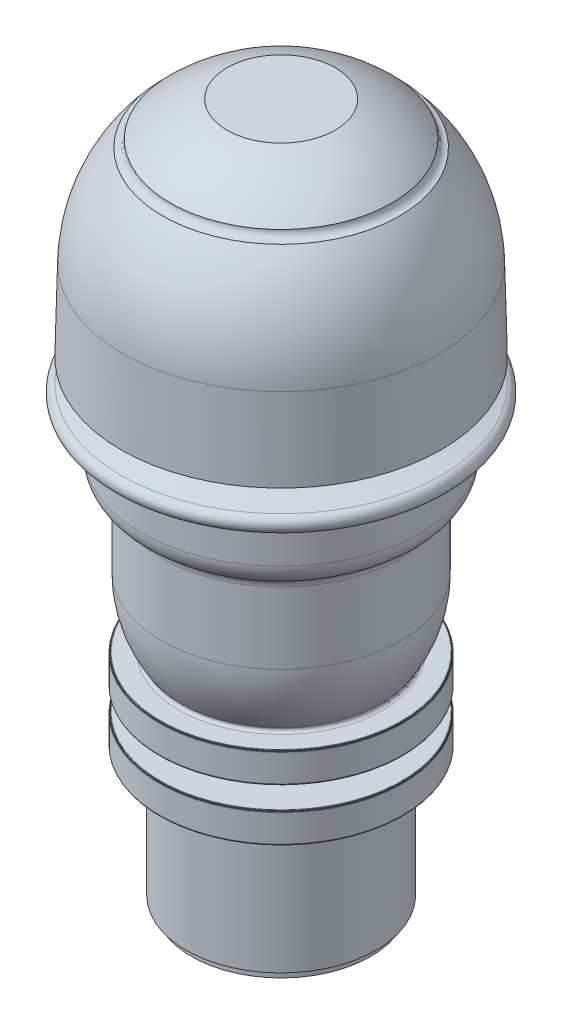
from build123d import *


with BuildPart() as part:
    # Croquis1 → Revolución1 (revolve)
    with BuildSketch(Plane.XY, mode=Mode.PRIVATE) as revoluci_n1_sk:
        with BuildLine():
            Line((0, 127.2), (-9.859453515, 127.2))
            ThreePointArc((-9.859453515, 127.2), (-15.384456376, 124.612652213), (-20.217918123, 120.890062694))
            ThreePointArc((-20.217918123, 120.890062694), (-20.613553833, 119.924642007), (-21.566984, 119.500925554))
            ThreePointArc((-21.566984, 119.500925554), (-26.819773718, 111.087572938), (-28.809846766, 101.370787909))
            Line((-28.809846766, 101.370787909), (-29.168600569, 86.4))
            Line((-29.168600569, 86.4), (-16.592882855, 86.4))
            ThreePointArc((-16.592882855, 86.4), (-16.498455664, 85.352786405), (-17.392882855, 84.8))
            Line((-17.392882855, 84.8), (-20.008439663, 84.8))
            Line((-20.008439663, 84.8), (-29.156111423, 82.348888739))
            ThreePointArc((-29.156111423, 82.348888739), (-30.216771595, 80.511771432), (-28.379654287, 79.451111261))
            Line((-28.379654287, 79.451111261), (-22.666523369, 79.451111261))
            Line((-22.666523369, 79.451111261), (-22.623739063, 77))
            Line((-22.623739063, 77), (-25.467882855, 77))
            Line((-25.467882855, 77), (-25.467882855, 71.441874699))
            ThreePointArc((-25.467882855, 71.441874699), (-24.784219197, 69.057429916), (-22.940959778, 67.397499907))
            ThreePointArc((-22.940959778, 67.397499907), (-22.12173337, 66.659753237), (-21.817882855, 65.6))
            Line((-21.817882855, 65.6), (-21.817882855, 52.6))
            ThreePointArc((-21.817882855, 52.6), (-20.897750352, 46.451917265), (-18.217985587, 40.842601269))
            ThreePointArc((-18.217985587, 40.842601269), (-18.188673208, 40.331971719), (-18.623547544, 40.062739356))
            Line((-18.623547544, 40.062739356), (-21.90136168, 40.005524898))
            Line((-21.90136168, 40.005524898), (-21.952286451, 40.000267041))
            Line((-21.952286451, 40.000267041), (-22.015296539, 39.980885632))
            Line((-22.015296539, 39.980885632), (-22.108638269, 39.917321663))
            Line((-22.108638269, 39.917321663), (-22.1735122, 39.819837263))
            Line((-22.1735122, 39.819837263), (-22.196125958, 39.705570589))
            Line((-22.196125958, 39.705570589), (-22.196125958, 34.794429411))
            Line((-22.196125958, 34.794429411), (-22.177246359, 34.689685343))
            Line((-22.177246359, 34.689685343), (-22.122762574, 34.597869384))
            Line((-22.122762574, 34.597869384), (-22.029158345, 34.525538385))
            Line((-22.029158345, 34.525538385), (-21.956818805, 34.50063292))
            Line((-21.956818805, 34.50063292), (-21.90136168, 34.494475102))
            Line((-21.90136168, 34.494475102), (-14.362647133, 34.36288635))
            ThreePointArc((-14.362647133, 34.36288635), (-14.15390772, 34.273204821), (-14.067882855, 34.062932042))
            Line((-14.067882855, 34.062932042), (-14.067882855, 30.937067958))
            ThreePointArc((-14.067882855, 30.937067958), (-14.15390772, 30.726795179), (-14.362647133, 30.63711365))
            Line((-14.362647133, 30.63711365), (-21.90136168, 30.505524898))
            Line((-21.90136168, 30.505524898), (-21.952286451, 30.500267041))
            Line((-21.952286451, 30.500267041), (-22.015296539, 30.480885632))
            Line((-22.015296539, 30.480885632), (-22.108638269, 30.417321663))
            Line((-22.108638269, 30.417321663), (-22.1735122, 30.319837263))
            Line((-22.1735122, 30.319837263), (-22.196125958, 30.205570589))
            Line((-22.196125958, 30.205570589), (-22.196125958, 25.294429411))
            Line((-22.196125958, 25.294429411), (-22.177246359, 25.189685343))
            Line((-22.177246359, 25.189685343), (-22.122762574, 25.097869384))
            Line((-22.122762574, 25.097869384), (-22.029158345, 25.025538385))
            Line((-22.029158345, 25.025538385), (-21.956818805, 25.00063292))
            Line((-21.956818805, 25.00063292), (-21.90136168, 24.994475102))
            Line((-21.90136168, 24.994475102), (-17.317882855, 24.914470182))
            Line((-17.317882855, 24.914470182), (-17.317882855, 1.5))
            Line((-17.317882855, 1.5), (-16.317882855, 1.5))
            Line((-16.317882855, 1.5), (-16.317882855, 0))
            Line((-16.317882855, 0), (0, 0))
            Line((0, 0), (0, 127.2))
        make_face()
    revolve(revoluci_n1_sk.sketch.rotate(Axis((0, 0, 0), (0, 1, 0)), 270), axis=Axis((0, 0, 0), (0, 1, 0)))


solid = part.part
